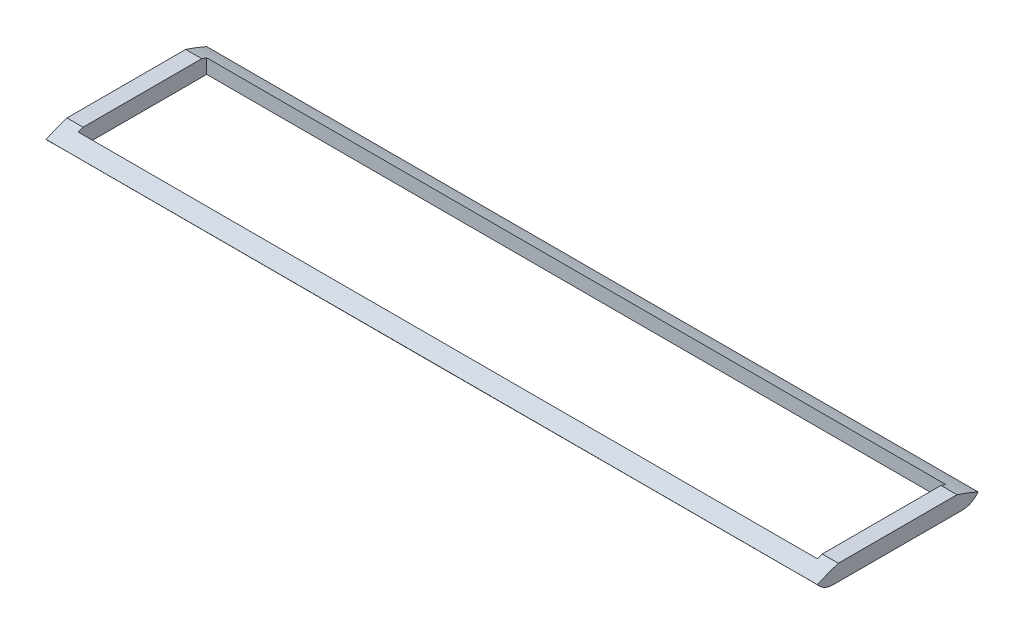
from build123d import *

# Parameters (mm, degrees)
SKETCH2_W           = 304.8
SKETCH2_H           = 63.5
SKETCH2_W_2         = 292.1
SKETCH2_H_2         = 50.8
BOSS_EXTRUDE1_DEPTH = 6.35
CUT_EXTRUDE1_DEPTH  = 305.8


with BuildPart() as part:
    # Sketch2 → Boss-Extrude1 (new body)
    with BuildSketch(Plane(origin=(0, 0, 0), x_dir=(1, 0, 0), z_dir=(0, 1, 0))):
        Rectangle(SKETCH2_W, SKETCH2_H)
        Rectangle(SKETCH2_W_2, SKETCH2_H_2, mode=Mode.SUBTRACT)
    extrude(amount=BOSS_EXTRUDE1_DEPTH)

    # Sketch3 → Cut-Extrude1 (cut, through all)
    with BuildSketch(Plane(origin=(152.4, 0, 0), x_dir=(0, 0, -1), z_dir=(1, 0, 0))):
        with BuildLine():
            Line((-25.4, 0), (-25.4, -8.736367268))
            Line((-25.4, -8.736367268), (-38.728215981, -8.736367268))
            Line((-38.728215981, -8.736367268), (-38.728215981, 15.541993339))
            Line((-38.728215981, 15.541993339), (38.923484297, 15.541993339))
            Line((38.923484297, 15.541993339), (38.923484297, -8.736367268))
            Line((38.923484297, -8.736367268), (25.4, -8.736367268))
            Line((25.4, -8.736367268), (25.4, 0))
            add(Edge.make_bspline(
                [(31.75, 3.175), (29.461898019, 0), (25.4, 0)],
                knots=[0, 0, 0, 1, 1, 1], degree=2))
            add(Edge.make_bspline(
                [(-31.75, 3.175), (0, 17.145), (31.75, 3.175)],
                knots=[0, 0, 0, 1, 1, 1], degree=2))
            add(Edge.make_bspline(
                [(-31.75, 3.175), (-29.216649895, 0), (-25.4, 0)],
                knots=[0, 0, 0, 1, 1, 1], degree=2))
        make_face()
    extrude(amount=-CUT_EXTRUDE1_DEPTH, mode=Mode.SUBTRACT)


solid = part.part
